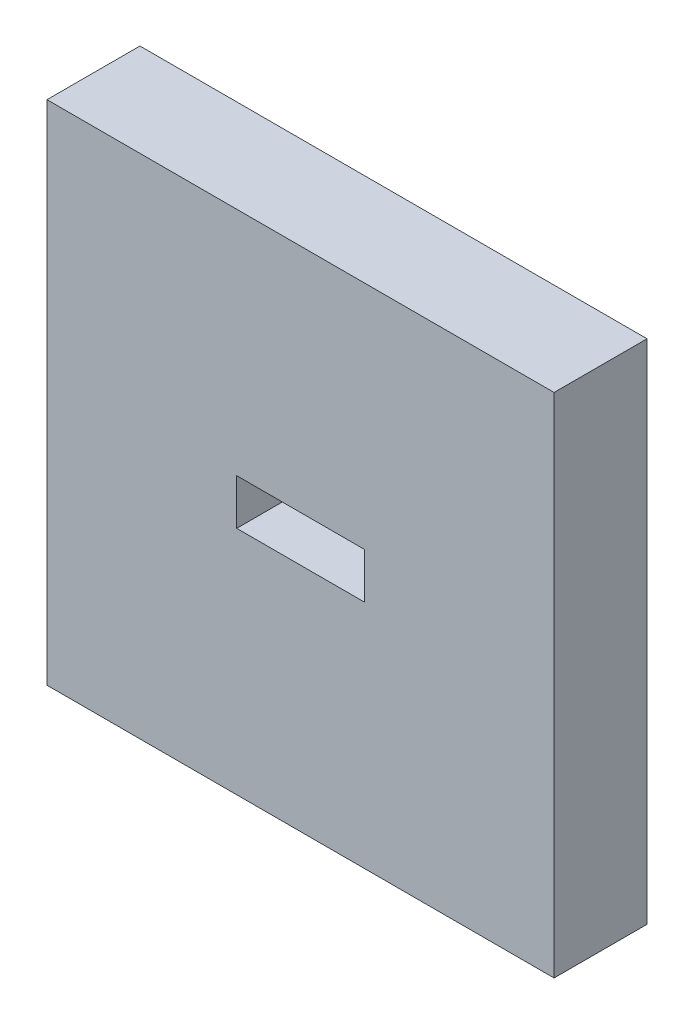
from build123d import *

# Parameters (mm, degrees)
SKETCH_1_W      = 600
SKETCH_1_H      = 600
SKETCH_1_W_2    = 151
SKETCH_1_H_2    = 54
EXTRUDE_1_DEPTH = 110


with BuildPart() as part:
    # Эскиз1 → Бобышка-Вытянуть1 (new body)
    with BuildSketch(Plane.XY):
        with Locations((75.5, 27)):
            Rectangle(SKETCH_1_W, SKETCH_1_H)
        with Locations((75.5, 27)):
            Rectangle(SKETCH_1_W_2, SKETCH_1_H_2, mode=Mode.SUBTRACT)
    extrude(amount=EXTRUDE_1_DEPTH)


solid = part.part
